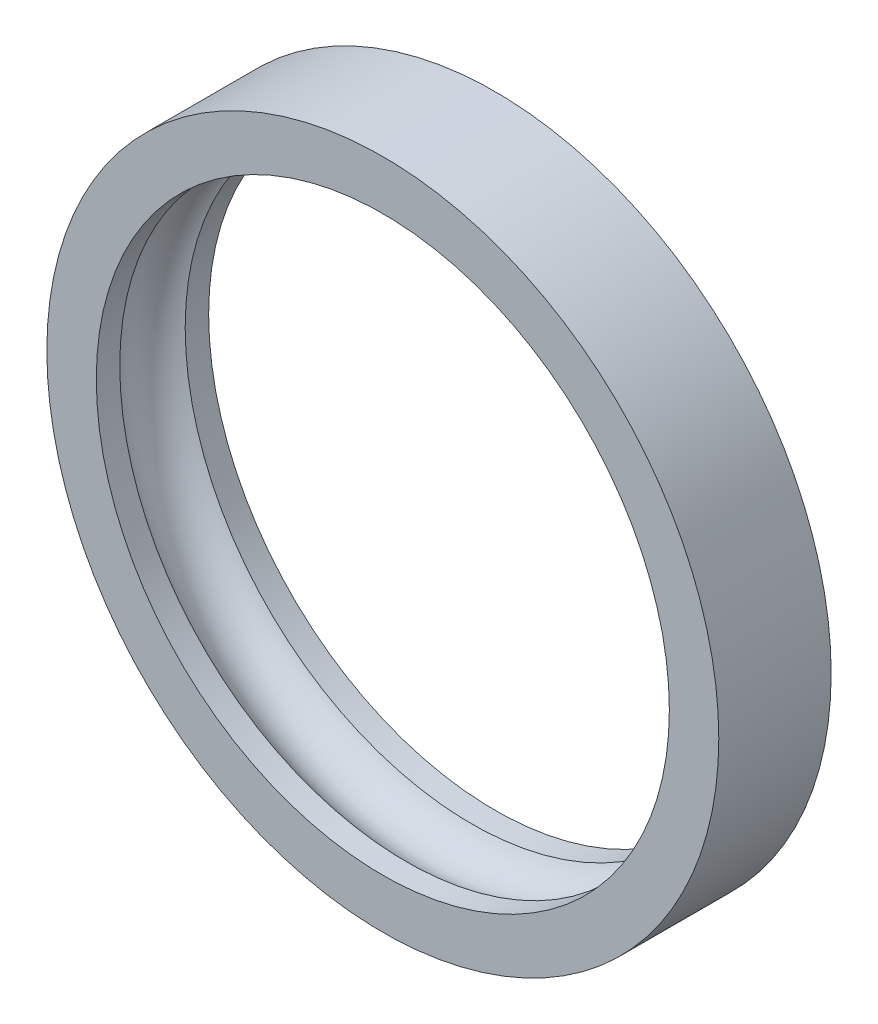
from build123d import *

# Parameters (mm, degrees)
SKETCH1_R           = 29.9
BOSS_EXTRUDE1_DEPTH = 10
CUT_EXTRUDE1_REACH  = 12
SKETCH2_R           = 25.5
SKETCH3_R           = 3.275


with BuildPart() as part:
    # Sketch1 → Boss-Extrude1 (new body)
    with BuildSketch(Plane.XY):
        Circle(SKETCH1_R)
    extrude(amount=BOSS_EXTRUDE1_DEPTH)

    # Sketch2 → Cut-Extrude1 (cut, up to next)
    with BuildSketch(Plane.XY.offset(10), mode=Mode.PRIVATE) as cut_extrude1_sk1:
        Circle(SKETCH2_R)
    cut_extrude1_tool1 = extrude(cut_extrude1_sk1.sketch, amount=-CUT_EXTRUDE1_REACH, mode=Mode.PRIVATE) & part.part
    add(cut_extrude1_tool1.solids().sort_by_distance((0, 0, 10))[0], mode=Mode.SUBTRACT)

    # Sketch3 → Cut-Revolve2 (revolve, cut)
    with BuildSketch(Plane(origin=(0, 0, 0), x_dir=(1, 0, 0), z_dir=(0, 1, 0))):
        with Locations((-24, -5)):
            Circle(SKETCH3_R)
    revolve(axis=Axis((0, 0, -18.462767292), (0, 0, 1)), mode=Mode.SUBTRACT)


solid = part.part
